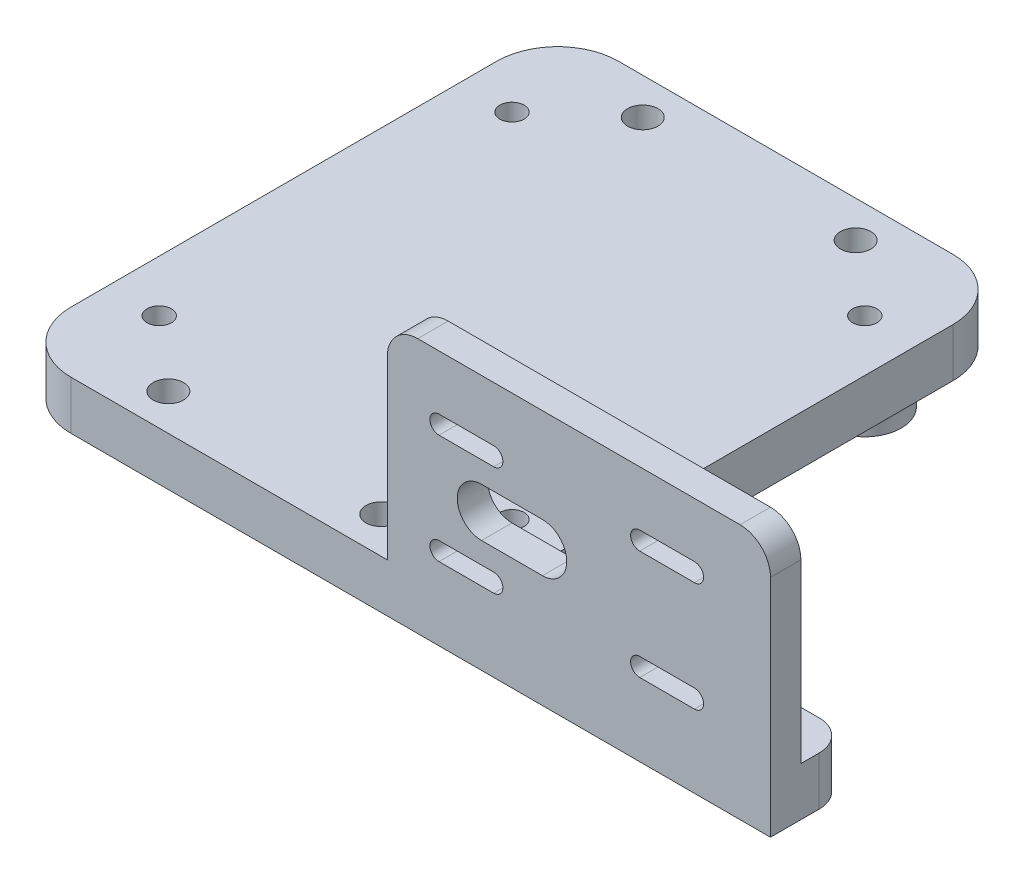
from build123d import *

# Parameters (mm, degrees)
SKETCH1_W               = 75
SKETCH1_H               = 90
SKETCH1_W_2             = 50
SKETCH1_H_2             = 13
BOSS_EXTRUDE1_DEPTH     = 8
SKETCH2_R               = 18
SKETCH2_R_2             = 15.5
BOSS_EXTRUDE2_DEPTH     = 5
SKETCH3_R               = 2
CUT_EXTRUDE2_DEPTH      = 6
CUT_EXTRUDE2_DEPTH_BACK = 9
FILLET2_R               = 10
FILLET3_R               = 10
FILLET4_R               = 10
CUT_EXTRUDE3_REACH      = 10
SKETCH5_R               = 2.5
SKETCH7_W               = 5
SKETCH7_H               = 34
BOSS_EXTRUDE3_DEPTH     = 63
FILLET5_R               = 5
FILLET6_R               = 5
FILLET7_R               = 5
CUT_EXTRUDE4_REACH      = 92
SKETCH13_R              = 6
SKETCH13_R_2            = 2
BOSS_EXTRUDE4_DEPTH     = 5


with BuildPart() as part:
    # Sketch1 → Boss-Extrude1 (new body)
    with BuildSketch(Plane(origin=(0, 0, 0), x_dir=(1, 0, 0), z_dir=(0, 1, 0))):
        with Locations((37.5, -45)):
            Rectangle(SKETCH1_W, SKETCH1_H)
        with Locations((100, -83.5)):
            Rectangle(SKETCH1_W_2, SKETCH1_H_2)
    extrude(amount=BOSS_EXTRUDE1_DEPTH)

    # Sketch2 → Boss-Extrude2 (add)
    with BuildSketch(Plane.XZ):
        with Locations((37.5, 45)):
            Circle(SKETCH2_R)
        with Locations((37.5, 45)):
            Circle(SKETCH2_R_2, mode=Mode.SUBTRACT)
    extrude(amount=BOSS_EXTRUDE2_DEPTH)

    # Sketch3 → Cut-Extrude2 (cut, two sides)
    with BuildSketch(Plane.XZ) as cut_extrude2_sk:
        with Locations((8.5, 74)):
            Circle(SKETCH3_R)
        with Locations((66.5, 74)):
            Circle(SKETCH3_R)
        with Locations((8.5, 16)):
            Circle(SKETCH3_R)
        with Locations((66.5, 16)):
            Circle(SKETCH3_R)
    extrude(amount=CUT_EXTRUDE2_DEPTH, mode=Mode.SUBTRACT)
    extrude(cut_extrude2_sk.sketch, amount=-CUT_EXTRUDE2_DEPTH_BACK, mode=Mode.SUBTRACT)

    # Fillet2
    fillet2_edges = [part.edges().sort_by_distance(p)[0] for p in [
        (0, 4, 0),
    ]]
    fillet(fillet2_edges, radius=FILLET2_R)

    # Fillet3
    fillet3_edges = [part.edges().sort_by_distance(p)[0] for p in [
        (0, 4, 90),
    ]]
    fillet(fillet3_edges, radius=FILLET3_R)

    # Fillet4
    fillet4_edges = [part.edges().sort_by_distance(p)[0] for p in [
        (75, 4, 0),
    ]]
    fillet(fillet4_edges, radius=FILLET4_R)

    # Sketch5 → Cut-Extrude3 (cut, up to next)
    with BuildSketch(Plane.XZ, mode=Mode.PRIVATE) as cut_extrude3_sk1:
        with Locations((55, 6)):
            Circle(SKETCH5_R)
    cut_extrude3_tool1 = extrude(cut_extrude3_sk1.sketch, amount=-CUT_EXTRUDE3_REACH, mode=Mode.PRIVATE) & part.part
    add(cut_extrude3_tool1.solids().sort_by_distance((55, 0, 6))[0], mode=Mode.SUBTRACT)
    # Sketch5 → Cut-Extrude3 (cut, up to next)
    with BuildSketch(Plane.XZ, mode=Mode.PRIVATE) as cut_extrude3_sk2:
        with Locations((20, 84)):
            Circle(SKETCH5_R)
    cut_extrude3_tool2 = extrude(cut_extrude3_sk2.sketch, amount=-CUT_EXTRUDE3_REACH, mode=Mode.PRIVATE) & part.part
    add(cut_extrude3_tool2.solids().sort_by_distance((20, 0, 84))[0], mode=Mode.SUBTRACT)
    # Sketch5 → Cut-Extrude3 (cut, up to next)
    with BuildSketch(Plane.XZ, mode=Mode.PRIVATE) as cut_extrude3_sk3:
        with Locations((55, 84)):
            Circle(SKETCH5_R)
    cut_extrude3_tool3 = extrude(cut_extrude3_sk3.sketch, amount=-CUT_EXTRUDE3_REACH, mode=Mode.PRIVATE) & part.part
    add(cut_extrude3_tool3.solids().sort_by_distance((55, 0, 84))[0], mode=Mode.SUBTRACT)
    # Sketch5 → Cut-Extrude3 (cut, up to next)
    with BuildSketch(Plane.XZ, mode=Mode.PRIVATE) as cut_extrude3_sk4:
        with Locations((20, 6)):
            Circle(SKETCH5_R)
    cut_extrude3_tool4 = extrude(cut_extrude3_sk4.sketch, amount=-CUT_EXTRUDE3_REACH, mode=Mode.PRIVATE) & part.part
    add(cut_extrude3_tool4.solids().sort_by_distance((20, 0, 6))[0], mode=Mode.SUBTRACT)

    # Sketch7 → Boss-Extrude3 (add)
    with BuildSketch(Plane(origin=(125, 0, 0), x_dir=(0, 0, -1), z_dir=(1, 0, 0))):
        with Locations((-87.5, 25)):
            Rectangle(SKETCH7_W, SKETCH7_H)
    extrude(amount=-BOSS_EXTRUDE3_DEPTH)

    # Fillet5
    fillet5_edges = [part.edges().sort_by_distance(p)[0] for p in [
        (125, 42, 87.5),
    ]]
    fillet(fillet5_edges, radius=FILLET5_R)

    # Fillet6
    fillet6_edges = [part.edges().sort_by_distance(p)[0] for p in [
        (125, 4, 77),
    ]]
    fillet(fillet6_edges, radius=FILLET6_R)

    # Fillet7
    fillet7_edges = [part.edges().sort_by_distance(p)[0] for p in [
        (62, 42, 87.5),
    ]]
    fillet(fillet7_edges, radius=FILLET7_R)

    # Sketch12 → Cut-Extrude4 (cut, up to next)
    with BuildSketch(Plane.XY.offset(90), mode=Mode.PRIVATE) as cut_extrude4_sk1:
        with BuildLine():
            Line((77.5, 26.5), (87.5, 26.5))
            ThreePointArc((87.5, 26.5), (91.5, 22.5), (87.5, 18.5))
            Line((87.5, 18.5), (77.5, 18.5))
            ThreePointArc((77.5, 18.5), (73.5, 22.5), (77.5, 26.5))
        make_face()
    cut_extrude4_tool1 = extrude(cut_extrude4_sk1.sketch, amount=-CUT_EXTRUDE4_REACH, mode=Mode.PRIVATE) & part.part
    add(cut_extrude4_tool1.solids().sort_by_distance((82.5, 22.5, 90))[0], mode=Mode.SUBTRACT)
    # Sketch12 → Cut-Extrude4 (cut, up to next)
    with BuildSketch(Plane.XY.offset(90), mode=Mode.PRIVATE) as cut_extrude4_sk2:
        with BuildLine():
            Line((70.5, 33), (79.5, 33))
            ThreePointArc((79.5, 33), (81, 31.5), (79.5, 30))
            Line((79.5, 30), (70.5, 30))
            ThreePointArc((70.5, 30), (69, 31.5), (70.5, 33))
        make_face()
    cut_extrude4_tool2 = extrude(cut_extrude4_sk2.sketch, amount=-CUT_EXTRUDE4_REACH, mode=Mode.PRIVATE) & part.part
    add(cut_extrude4_tool2.solids().sort_by_distance((75, 31.5, 90))[0], mode=Mode.SUBTRACT)
    # Sketch12 → Cut-Extrude4 (cut, up to next)
    with BuildSketch(Plane.XY.offset(90), mode=Mode.PRIVATE) as cut_extrude4_sk3:
        with BuildLine():
            Line((70.5, 12), (79.5, 12))
            ThreePointArc((79.5, 12), (81, 13.5), (79.5, 15))
            Line((79.5, 15), (70.5, 15))
            ThreePointArc((70.5, 15), (69, 13.5), (70.5, 12))
        make_face()
    cut_extrude4_tool3 = extrude(cut_extrude4_sk3.sketch, amount=-CUT_EXTRUDE4_REACH, mode=Mode.PRIVATE) & part.part
    add(cut_extrude4_tool3.solids().sort_by_distance((75, 13.5, 90))[0], mode=Mode.SUBTRACT)
    # Sketch12 → Cut-Extrude4 (cut, up to next)
    with BuildSketch(Plane.XY.offset(90), mode=Mode.PRIVATE) as cut_extrude4_sk4:
        with BuildLine():
            Line((103.5, 33), (112.5, 33))
            ThreePointArc((112.5, 33), (114, 31.5), (112.5, 30))
            Line((112.5, 30), (103.5, 30))
            ThreePointArc((103.5, 30), (102, 31.5), (103.5, 33))
        make_face()
    cut_extrude4_tool4 = extrude(cut_extrude4_sk4.sketch, amount=-CUT_EXTRUDE4_REACH, mode=Mode.PRIVATE) & part.part
    add(cut_extrude4_tool4.solids().sort_by_distance((108, 31.5, 90))[0], mode=Mode.SUBTRACT)
    # Sketch12 → Cut-Extrude4 (cut, up to next)
    with BuildSketch(Plane.XY.offset(90), mode=Mode.PRIVATE) as cut_extrude4_sk5:
        with BuildLine():
            Line((103.5, 12), (112.5, 12))
            ThreePointArc((112.5, 12), (114, 13.5), (112.5, 15))
            Line((112.5, 15), (103.5, 15))
            ThreePointArc((103.5, 15), (102, 13.5), (103.5, 12))
        make_face()
    cut_extrude4_tool5 = extrude(cut_extrude4_sk5.sketch, amount=-CUT_EXTRUDE4_REACH, mode=Mode.PRIVATE) & part.part
    add(cut_extrude4_tool5.solids().sort_by_distance((108, 13.5, 90))[0], mode=Mode.SUBTRACT)

    # Sketch13 → Boss-Extrude4 (add)
    with BuildSketch(Plane.XZ):
        with Locations((8.5, 74)):
            Circle(SKETCH13_R)
        with Locations((8.5, 74)):
            Circle(SKETCH13_R_2, mode=Mode.SUBTRACT)
        with Locations((66.5, 74)):
            Circle(SKETCH13_R)
        with Locations((66.5, 74)):
            Circle(SKETCH13_R_2, mode=Mode.SUBTRACT)
        with Locations((66.5, 16)):
            Circle(SKETCH13_R)
        with Locations((66.5, 16)):
            Circle(SKETCH13_R_2, mode=Mode.SUBTRACT)
        with Locations((8.5, 16)):
            Circle(SKETCH13_R)
        with Locations((8.5, 16)):
            Circle(SKETCH13_R_2, mode=Mode.SUBTRACT)
    extrude(amount=BOSS_EXTRUDE4_DEPTH)


solid = part.part
